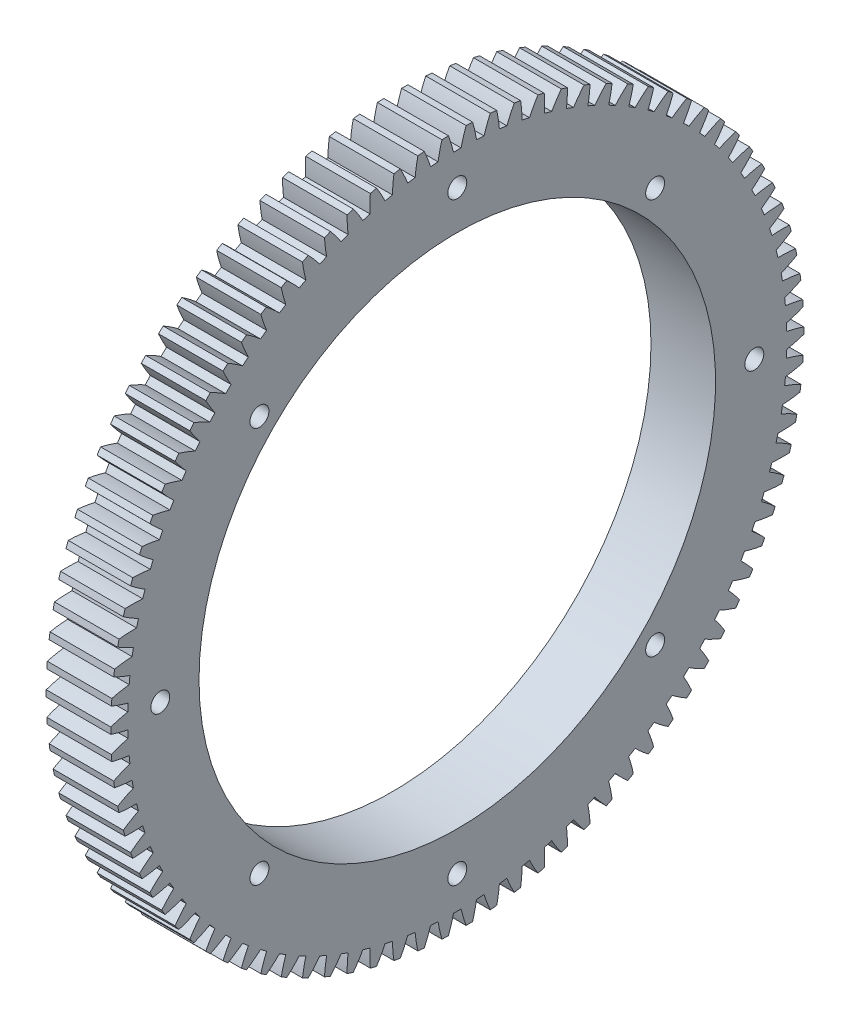
from build123d import *

# Parameters (mm, degrees)
BASPROSKE_W        = 15
BASPROSKE_H        = 80.5
TOOTHCUT_DEPTH     = 115.828132441
TEETHCUTS_COUNT    = 90
TEETHCUTS_ANGLE    = 356
BORSKE_R           = 60
BORE_DEPTH         = 50.0000508
SKETCH1_R          = 2.2
CUT_EXTRUDE1_DEPTH = 15
SKETCH1_4_R        = 4
CUT_EXTRUDE2_DEPTH = 5
SKETCH1_5_R        = 4
SKETCH1_5_R_2      = 2.2
CUT_EXTRUDE3_DEPTH = 7


with BuildPart() as part:
    # BasProSke → Base-Revolve (revolve)
    with BuildSketch(Plane(origin=(0, 0, 0), x_dir=(1, 0, 0), z_dir=(0, 1, 0)), mode=Mode.PRIVATE) as base_revolve_sk:
        with Locations((7.5, 40.25)):
            Rectangle(BASPROSKE_W, BASPROSKE_H)
    revolve(base_revolve_sk.sketch.rotate(Axis((-10, 0, 0), (1, 0, 0)), 180), axis=Axis((-10, 0, 0), (1, 0, 0)))

    # TooCutSke → ToothCut (cut, through all)
    with BuildSketch(Plane(origin=(0, 0, 0), x_dir=(0, 0, -1), z_dir=(1, 0, 0))):
        with BuildLine():
            ThreePointArc((0.875877476, 76.556489737), (0, 76.5615), (-0.875877476, 76.556489737))
            ThreePointArc((-0.875877476, 76.556489737), (-1.409116534, 78.54718631), (-2.071385355, 80.498754077))
            ThreePointArc((-2.071385355, 80.498754077), (0, 80.5254), (2.071385355, 80.498754077))
            ThreePointArc((2.071385355, 80.498754077), (1.409116534, 78.54718631), (0.875877476, 76.556489737))
        make_face()
    toothcut = extrude(amount=TOOTHCUT_DEPTH, mode=Mode.SUBTRACT)

    # TeethCuts: ToothCut ×90 about axis
    teethcuts_axis = Axis((-10, 0, 0), (1, 0, 0))
    for i in range(1, TEETHCUTS_COUNT):
        add(toothcut.rotate(teethcuts_axis, i * TEETHCUTS_ANGLE / (TEETHCUTS_COUNT - 1)), mode=Mode.SUBTRACT)

    # BorSke → Bore (cut, symmetric)
    with BuildSketch(Plane(origin=(0, 0, 0), x_dir=(0, 0, -1), z_dir=(1, 0, 0))):
        with Locations(Location((0, 0, 0), (0, 0, 180))):
            Circle(BORSKE_R)
    extrude(amount=BORE_DEPTH, both=True, mode=Mode.SUBTRACT)

    # Sketch1 → Cut-Extrude1 (cut)
    with BuildSketch(Plane(origin=(0, 0, 0), x_dir=(0, 0, -1), z_dir=(1, 0, 0))):
        with Locations((0, 69)):
            Circle(SKETCH1_R)
        with Locations((69.001, 0.001)):
            Circle(SKETCH1_R)
        with Locations((0.002, -69)):
            Circle(SKETCH1_R)
        with Locations((-68.999, -0.001)):
            Circle(SKETCH1_R)
        with Locations((45.961940777, 45.961940777)):
            Circle(SKETCH1_R)
        with Locations((45.961940777, -45.961940777)):
            Circle(SKETCH1_R)
        with Locations((-45.961940777, -45.961940777)):
            Circle(SKETCH1_R)
        with Locations((-45.961940777, 45.961940777)):
            Circle(SKETCH1_R)
    extrude(amount=CUT_EXTRUDE1_DEPTH, mode=Mode.SUBTRACT)

    # Sketch1_4 → Cut-Extrude2 (cut)
    with BuildSketch(Plane(origin=(0, 0, 0), x_dir=(0, 0, -1), z_dir=(1, 0, 0))):
        with Locations((0, 69)):
            Circle(SKETCH1_4_R)
        with Locations((69.001, 0.001)):
            Circle(SKETCH1_4_R)
        with Locations((0.002, -69)):
            Circle(SKETCH1_4_R)
        with Locations((-68.999, -0.001)):
            Circle(SKETCH1_4_R)
    extrude(amount=CUT_EXTRUDE2_DEPTH, mode=Mode.SUBTRACT)

    # Sketch1_5 → Cut-Extrude3 (cut)
    with BuildSketch(Plane(origin=(0, 0, 0), x_dir=(0, 0, -1), z_dir=(1, 0, 0))):
        with Locations((45.961940777, -45.961940777)):
            Circle(SKETCH1_5_R)
        with Locations((45.961940777, -45.961940777)):
            Circle(SKETCH1_5_R_2, mode=Mode.SUBTRACT)
        with Locations((45.961940777, 45.961940777)):
            Circle(SKETCH1_5_R)
        with Locations((45.961940777, 45.961940777)):
            Circle(SKETCH1_5_R_2, mode=Mode.SUBTRACT)
        with Locations((-45.961940777, 45.961940777)):
            Circle(SKETCH1_5_R)
        with Locations((-45.961940777, 45.961940777)):
            Circle(SKETCH1_5_R_2, mode=Mode.SUBTRACT)
        with Locations((-45.961940777, -45.961940777)):
            Circle(SKETCH1_5_R)
        with Locations((-45.961940777, -45.961940777)):
            Circle(SKETCH1_5_R_2, mode=Mode.SUBTRACT)
    extrude(amount=CUT_EXTRUDE3_DEPTH, mode=Mode.SUBTRACT)


solid = part.part
